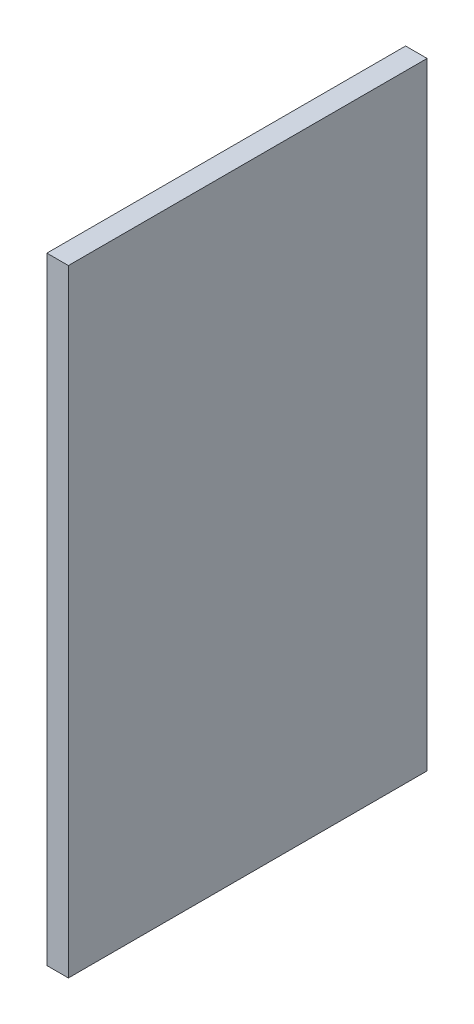
from build123d import *

# Parameters (mm, degrees)
ESBO_O1_W                = 250
ESBO_O1_H                = 430
RESSALTO_EXTRUS_O1_DEPTH = 15
REVOLU_O1_ANGLE          = 180


with BuildPart() as part:
    # Esboço1 → Ressalto-extrusão1 (new body)
    with BuildSketch(Plane(origin=(0, 0, 0), x_dir=(0, 0, -1), z_dir=(1, 0, 0))):
        Rectangle(ESBO_O1_W, ESBO_O1_H)
    extrude(amount=RESSALTO_EXTRUS_O1_DEPTH)

    # Esboço4 → Revolução1 (revolve)
    with BuildSketch(Plane.ZY):
        with BuildLine():
            Line((-25, 0), (25, 0))
            ThreePointArc((25, 0), (0, -25), (-25, 0))
        make_face()
    revolve(axis=Axis((0, 0, -25), (0, 0, -1)), revolution_arc=REVOLU_O1_ANGLE)


solid = part.part
